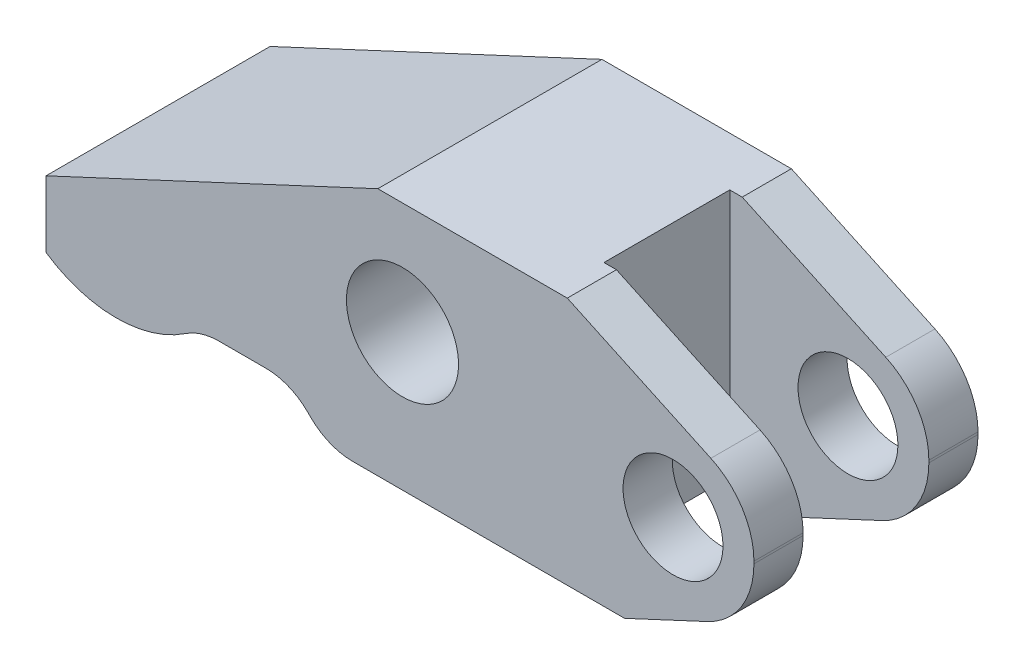
from build123d import *

# Parameters (mm, degrees)
SKETCH2_W               = 56.896
SKETCH2_H               = 18.0086
BOSS_EXTRUDE1_DEPTH     = 9.9949
SKETCH3_R               = 4.01574
SKETCH3_R_2             = 4.50596
CUT_EXTRUDE1_DEPTH      = 10.0043
CUT_EXTRUDE1_DEPTH_BACK = 10.0043
SKETCH5_OUTSIDE_W       = 71.484
SKETCH5_OUTSIDE_H       = 34.578
CUT_EXTRUDE2_DEPTH      = 10.0043
CUT_EXTRUDE2_DEPTH_BACK = 10.0043
CUT_EXTRUDE3_DEPTH      = 10.0043
CUT_EXTRUDE3_DEPTH_BACK = 10.0043
FILLET1_R               = 4.7752
SKETCH7_W               = 16.002
SKETCH7_H               = 10.1092
CUT_EXTRUDE4_DEPTH      = 10.9949
CUT_EXTRUDE4_DEPTH_BACK = 10.9949


with BuildPart() as part:
    # Sketch2 → Boss-Extrude1 (new body, symmetric)
    with BuildSketch(Plane(origin=(0, 0, 0), x_dir=(1, 0, 0), z_dir=(0, 1, 0))):
        Rectangle(SKETCH2_W, SKETCH2_H)
    extrude(amount=BOSS_EXTRUDE1_DEPTH, both=True)

    # Sketch3 → Cut-Extrude1 (cut, two sides)
    with BuildSketch(Plane.XY) as cut_extrude1_sk:
        with Locations((21.9456, -1.0033)):
            Circle(SKETCH3_R)
        with Locations((0.2032, 1.0033)):
            Circle(SKETCH3_R_2)
    extrude(amount=CUT_EXTRUDE1_DEPTH, mode=Mode.SUBTRACT)
    extrude(cut_extrude1_sk.sketch, amount=-CUT_EXTRUDE1_DEPTH_BACK, mode=Mode.SUBTRACT)

    # Sketch5 outside → Cut-Extrude2 (cut, two sides)
    with BuildSketch(Plane.XY) as cut_extrude2_sk:
        Rectangle(SKETCH5_OUTSIDE_W, SKETCH5_OUTSIDE_H)
        with BuildLine():
            Line((18.049040748, -9.9949), (24.693632985, -6.896475754))
            ThreePointArc((24.693632985, -6.896475754), (27.429668537, -4.497036973), (28.448, -1.0033))
            Line((28.448, -1.0033), (28.448, -0.818554854))
            ThreePointArc((28.448, -0.818554854), (27.509225683, 2.402233918), (24.986942908, 4.614216544))
            Line((24.986942908, 4.614216544), (13.44803, 9.9949))
            Line((13.44803, 9.9949), (-1.778, 9.9949))
            Line((-1.778, 9.9949), (-28.448, -2.441525243))
            Line((-28.448, -2.441525243), (-28.448, -9.9949))
            Line((-28.448, -9.9949), (18.049040748, -9.9949))
        make_face(mode=Mode.SUBTRACT)
    extrude(amount=CUT_EXTRUDE2_DEPTH, mode=Mode.SUBTRACT)
    extrude(cut_extrude2_sk.sketch, amount=-CUT_EXTRUDE2_DEPTH_BACK, mode=Mode.SUBTRACT)

    # Sketch6 → Cut-Extrude3 (cut, two sides)
    with BuildSketch(Plane.XY) as cut_extrude3_sk:
        with BuildLine():
            Line((-5.7912, -9.9949), (-8.7884, -6.9977))
            Line((-8.7884, -6.9977), (-16.175422135, -6.9977))
            ThreePointArc((-16.175422135, -6.9977), (-22.178675052, -9.492417259), (-28.448, -7.772468279))
            Line((-28.448, -7.772468279), (-28.448, -9.9949))
            Line((-28.448, -9.9949), (-5.7912, -9.9949))
        make_face()
    extrude(amount=CUT_EXTRUDE3_DEPTH, mode=Mode.SUBTRACT)
    extrude(cut_extrude3_sk.sketch, amount=-CUT_EXTRUDE3_DEPTH_BACK, mode=Mode.SUBTRACT)

    # Fillet1
    fillet1_edges = [part.edges().sort_by_distance(p)[0] for p in [
        (-16.175422135, -6.9977, 0),
        (-8.7884, -6.9977, 0),
        (-5.7912, -9.9949, 0),
    ]]
    fillet(fillet1_edges, radius=FILLET1_R)

    # Sketch7 → Cut-Extrude4 (cut, two sides)
    with BuildSketch(Plane(origin=(0, 0, 0), x_dir=(1, 0, 0), z_dir=(0, 1, 0))) as cut_extrude4_sk:
        with Locations((20.447, 0)):
            Rectangle(SKETCH7_W, SKETCH7_H)
    extrude(amount=CUT_EXTRUDE4_DEPTH, mode=Mode.SUBTRACT)
    extrude(cut_extrude4_sk.sketch, amount=-CUT_EXTRUDE4_DEPTH_BACK, mode=Mode.SUBTRACT)


solid = part.part
